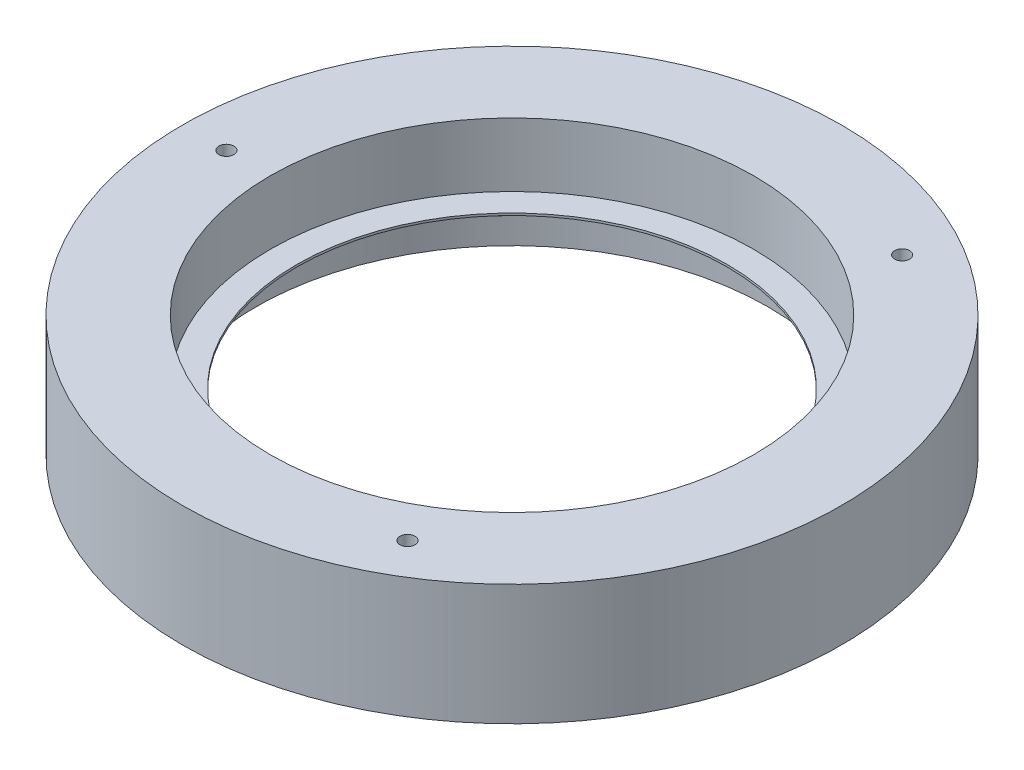
from build123d import *

# Parameters (mm, degrees)
CROQUIS2_R            = 1.7
CORTAR_EXTRUIR1_DEPTH = 59
MATRIZC1_COUNT        = 3


with BuildPart() as part:
    # Croquis1 → Revolución1 (revolve)
    with BuildSketch(Plane.XY):
        Polygon((58.282962044, 6), (58.282962044, 0), (75, 0), (75, 27.5), (55, 27.5), (55, 13), (49, 13), (49, 12.5), align=None)
    revolve(axis=Axis((0, 0, 0), (0, 1, 0)))

    # Croquis2 → Cortar-Extruir1 (cut)
    with BuildSketch(Plane(origin=(0, 27.5, 0), x_dir=(1, 0, 0), z_dir=(0, 1, 0))):
        with Locations((-65, 0)):
            Circle(CROQUIS2_R)
    cortar_extruir1 = extrude(amount=-CORTAR_EXTRUIR1_DEPTH, mode=Mode.SUBTRACT)

    # MatrizC1: Cortar-Extruir1 ×3 about axis
    matrizc1_axis = Axis((0, 0, 0), (0, 1, 0))
    for i in range(1, MATRIZC1_COUNT):
        add(cortar_extruir1.rotate(matrizc1_axis, i * 360 / MATRIZC1_COUNT), mode=Mode.SUBTRACT)


solid = part.part
